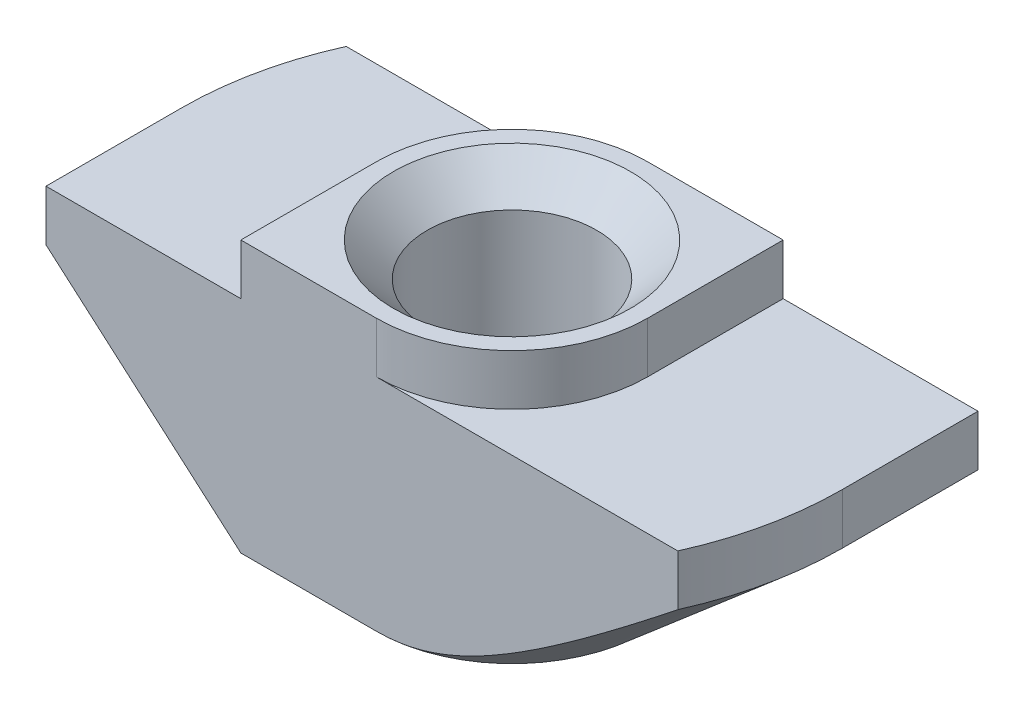
from build123d import *

# Parameters (mm, degrees)
EXTRUDE_1_DEPTH     = 4
CUT_EXTRUDE_1_DEPTH = 1.5
CUT_EXTRUDE_2_DEPTH = 7.5


with BuildPart() as part:
    # Эскиз1 → Бобышка-Вытянуть1 (new body, symmetric)
    with BuildSketch(Plane.XY):
        Polygon((4, 0), (-4, 0), (-4, -1.5), (-9.75, -1.5), (-9.75, -8), (9.75, -8), (9.75, -1.5), (4, -1.5), align=None)
    extrude(amount=EXTRUDE_1_DEPTH, both=True)

    # Эскиз3 → Отверстие обработанное метчиком M62 (revolve, cut)
    with BuildSketch(Plane(origin=(0, 0, 0), x_dir=(0, 0, 1), z_dir=(1, 0, 0))):
        Polygon((0, 0), (0, 8), (3.5, 8), (2.5, 7), (2.5, 1), (3.5, 0), align=None)
    revolve(axis=Axis((0, 6.35, 0), (0, -1, 0)), mode=Mode.SUBTRACT)

    # Эскиз4 → Вырез-Вытянуть1 (cut)
    with BuildSketch(Plane(origin=(0, 0, 0), x_dir=(1, 0, 0), z_dir=(0, 1, 0))):
        with BuildLine():
            Line((-4, 4), (-4, 0))
            ThreePointArc((-4, 0), (-2.828427125, 2.828427125), (0, 4))
            Line((0, 4), (-4, 4))
        make_face()
        with BuildLine():
            Line((0, -4), (4, -4))
            Line((4, -4), (4, 0))
            ThreePointArc((4, 0), (2.828427125, -2.828427125), (0, -4))
        make_face()
    extrude(amount=-CUT_EXTRUDE_1_DEPTH, mode=Mode.SUBTRACT)

    # Эскиз5 → Вырез-Вытянуть2 (cut, through all)
    with BuildSketch(Plane(origin=(0, -1.5, 0), x_dir=(1, 0, 0), z_dir=(0, 1, 0))):
        with BuildLine():
            Line((-9.75, 0), (-9.75, 4))
            Line((-9.75, 4), (-8.891709622, 4))
            ThreePointArc((-8.891709622, 4), (-9.533012871, 2.045523305), (-9.75, 0))
        make_face()
        with BuildLine():
            Line((9.75, 0), (9.75, -4))
            Line((9.75, -4), (8.891709622, -4))
            ThreePointArc((8.891709622, -4), (9.533012871, -2.045523305), (9.75, 0))
        make_face()
    extrude(amount=-CUT_EXTRUDE_2_DEPTH, mode=Mode.SUBTRACT)

    # Вырез-По траектории1: sweep along a path in Эскиз7
    with BuildLine(Plane.XZ.offset(8)) as sweep_1_path:
        Line((0, 9.75), (-9.75, 9.75))
        Line((-9.75, 9.75), (-9.75, 0))
        ThreePointArc((-9.75, 0), (-6.894291117, -6.894291117), (0, -9.75))
        Line((0, -9.75), (9.75, -9.75))
        Line((9.75, -9.75), (9.75, 0))
        ThreePointArc((9.75, 0), (6.894291117, 6.894291117), (0, 9.75))
    # Эскиз6 → Вырез-По траектории1 (sweep, cut)
    with BuildSketch(Plane.XY.offset(4)):
        Polygon((-9.75, -3), (-9.75, -8), (-4, -8), align=None)
    sweep(path=sweep_1_path.line, transition=Transition.RIGHT, mode=Mode.SUBTRACT)


solid = part.part
